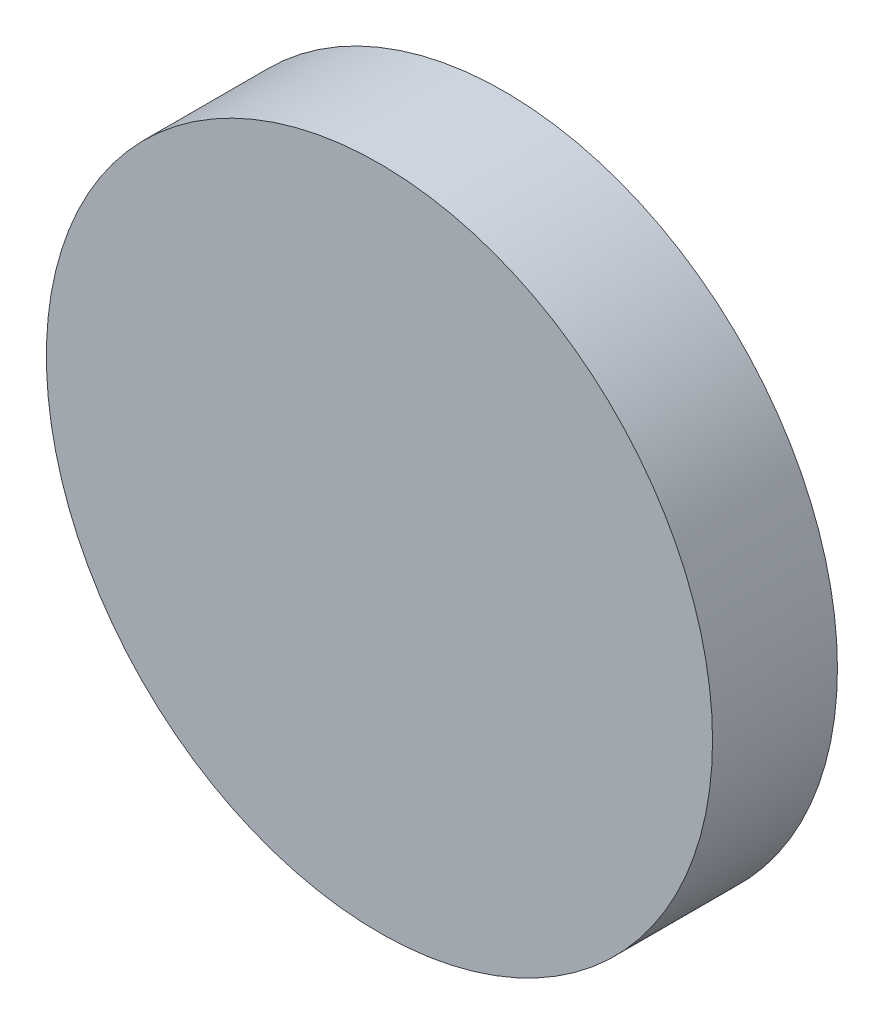
from build123d import *

# Parameters (mm, degrees)
SKETCH1_R           = 8
BOSS_EXTRUDE1_DEPTH = 3


with BuildPart() as part:
    # Sketch1 → Boss-Extrude1 (new body)
    with BuildSketch(Plane.XY):
        Circle(SKETCH1_R)
    extrude(amount=BOSS_EXTRUDE1_DEPTH)


solid = part.part
